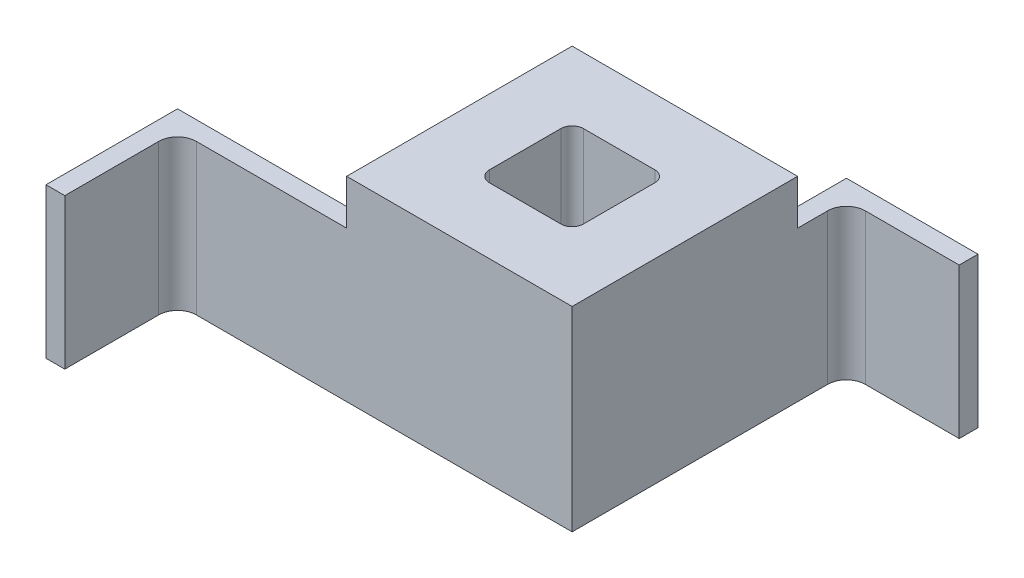
from build123d import *

# Parameters (mm, degrees)
SKETCH1_W           = 60
SKETCH1_H           = 60
BOSS_EXTRUDE1_DEPTH = 51.95
SKETCH3_W           = 5
SKETCH3_H           = 40
BOSS_EXTRUDE2_DEPTH = 18
SKETCH4_W           = 5
SKETCH4_H           = 40
BOSS_EXTRUDE3_DEPTH = 30
SKETCH5_W           = 5
SKETCH5_H           = 40
BOSS_EXTRUDE4_DEPTH = 50
SKETCH6_W           = 5
SKETCH6_H           = 40
BOSS_EXTRUDE5_DEPTH = 30
SKETCH7_W           = 25
SKETCH7_H           = 25
CUT_EXTRUDE1_DEPTH  = 52.95
FILLET1_R           = 3
FILLET2_R           = 5
FILLET3_R           = 5


with BuildPart() as part:
    # Sketch1 → Boss-Extrude1 (new body)
    with BuildSketch(Plane(origin=(0, 0, 0), x_dir=(1, 0, 0), z_dir=(0, 1, 0))):
        Rectangle(SKETCH1_W, SKETCH1_H)
    extrude(amount=BOSS_EXTRUDE1_DEPTH)

    # Sketch3 → Boss-Extrude2 (add)
    with BuildSketch(Plane(origin=(0, 0, -30), x_dir=(-1, 0, 0), z_dir=(0, 0, -1))):
        with Locations((-27.5, 20)):
            Rectangle(SKETCH3_W, SKETCH3_H)
    extrude(amount=BOSS_EXTRUDE2_DEPTH)

    # Sketch4 → Boss-Extrude3 (add)
    with BuildSketch(Plane(origin=(30, 0, 0), x_dir=(0, 0, -1), z_dir=(1, 0, 0))):
        with Locations((45.5, 20)):
            Rectangle(SKETCH4_W, SKETCH4_H)
    extrude(amount=BOSS_EXTRUDE3_DEPTH)

    # Sketch5 → Boss-Extrude4 (add)
    with BuildSketch(Plane.ZY.offset(30)):
        with Locations((27.5, 20)):
            Rectangle(SKETCH5_W, SKETCH5_H)
    extrude(amount=BOSS_EXTRUDE4_DEPTH)

    # Sketch6 → Boss-Extrude5 (add)
    with BuildSketch(Plane.XY.offset(30)):
        with Locations((-77.5, 20)):
            Rectangle(SKETCH6_W, SKETCH6_H)
    extrude(amount=BOSS_EXTRUDE5_DEPTH)

    # Sketch7 → Cut-Extrude1 (cut, through all)
    with BuildSketch(Plane(origin=(0, 51.95, 0), x_dir=(1, 0, 0), z_dir=(0, 1, 0))):
        Rectangle(SKETCH7_W, SKETCH7_H)
    extrude(amount=-CUT_EXTRUDE1_DEPTH, mode=Mode.SUBTRACT)

    # Fillet1
    fillet1_edges = [part.edges().sort_by_distance(p)[0] for p in [
        (12.5, 25.975, -12.5),
        (12.5, 25.975, 12.5),
        (-12.5, 25.975, 12.5),
        (-12.5, 25.975, -12.5),
    ]]
    fillet(fillet1_edges, radius=FILLET1_R)

    # Fillet2
    fillet2_edges = [part.edges().sort_by_distance(p)[0] for p in [
        (30, 20, -43),
        (-75, 20, 30),
    ]]
    fillet(fillet2_edges, radius=FILLET2_R)

    # Fillet3
    fillet3_edges = [part.edges().sort_by_distance(p)[0] for p in [
        (25, 20, -30),
        (-30, 20, 25),
    ]]
    fillet(fillet3_edges, radius=FILLET3_R)


solid = part.part
